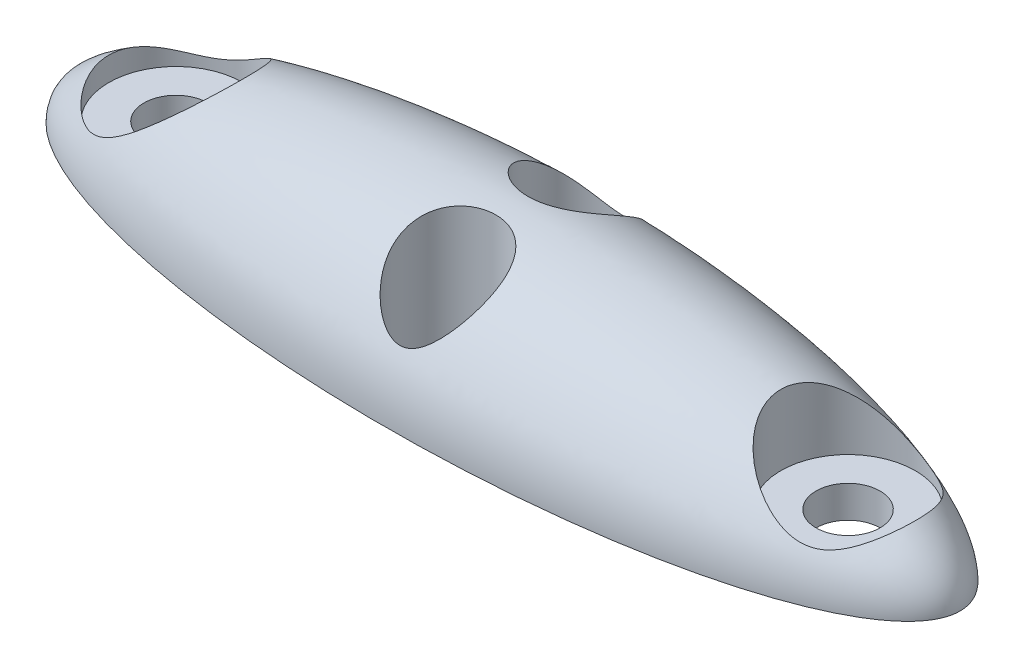
from build123d import *

# Parameters (mm, degrees)
SKETCH2_W               = 50.634745493
SKETCH2_H               = 13.07277583
CUT_EXTRUDE1_DEPTH      = 5.0000001
CUT_EXTRUDE1_DEPTH_BACK = 5.0000001
SKETCH3_R               = 1
CUT_EXTRUDE2_DEPTH      = 5.0000001
SKETCH4_R               = 2.1
CUT_EXTRUDE3_DEPTH      = 4.0000001
SKETCH5_R               = 1.5
CUT_EXTRUDE4_DEPTH      = 5.0000001


with BuildPart() as part:
    # Sketch1 → Revolve1 (revolve)
    with BuildSketch(Plane.XY):
        with BuildLine():
            Line((-14, 0), (14, 0))
            add(Edge.make_bspline(
                [(14, 0), (14, 4), (0, 4), (-14, 4), (-14, 0)],
                knots=[0, 0, 0, 1.570796327, 1.570796327, 3.141592654, 3.141592654, 3.141592654], degree=2, weights=[1, 0.707106781, 1, 0.707106781, 1]))
        make_face()
    revolve(axis=Axis((-14, 0, 0), (1, 0, 0)))

    # Sketch2 → Cut-Extrude1 (cut, two sides)
    with BuildSketch(Plane.XY) as cut_extrude1_sk:
        with Locations((-1.598405816, -6.536387915)):
            Rectangle(SKETCH2_W, SKETCH2_H)
    extrude(amount=CUT_EXTRUDE1_DEPTH, mode=Mode.SUBTRACT)
    extrude(cut_extrude1_sk.sketch, amount=-CUT_EXTRUDE1_DEPTH_BACK, mode=Mode.SUBTRACT)

    # Sketch3 → Cut-Extrude2 (cut, through all)
    with BuildSketch(Plane.XZ):
        with Locations((-10.5, 0)):
            Circle(SKETCH3_R)
        with Locations((10.5, 0)):
            Circle(SKETCH3_R)
    extrude(amount=-CUT_EXTRUDE2_DEPTH, mode=Mode.SUBTRACT)

    # Sketch4 → Cut-Extrude3 (cut, through all)
    with BuildSketch(Plane(origin=(0, 1, 0), x_dir=(-1, 0, 0), z_dir=(0, -1, 0))):
        with Locations((10.5, 0)):
            Circle(SKETCH4_R)
        with Locations((-10.5, 0)):
            Circle(SKETCH4_R)
    extrude(amount=-CUT_EXTRUDE3_DEPTH, mode=Mode.SUBTRACT)

    # Sketch5 → Cut-Extrude4 (cut, through all)
    with BuildSketch(Plane.XZ):
        with Locations((0, 2)):
            Circle(SKETCH5_R)
        with Locations((0, -2)):
            Circle(SKETCH5_R)
    extrude(amount=-CUT_EXTRUDE4_DEPTH, mode=Mode.SUBTRACT)


solid = part.part
